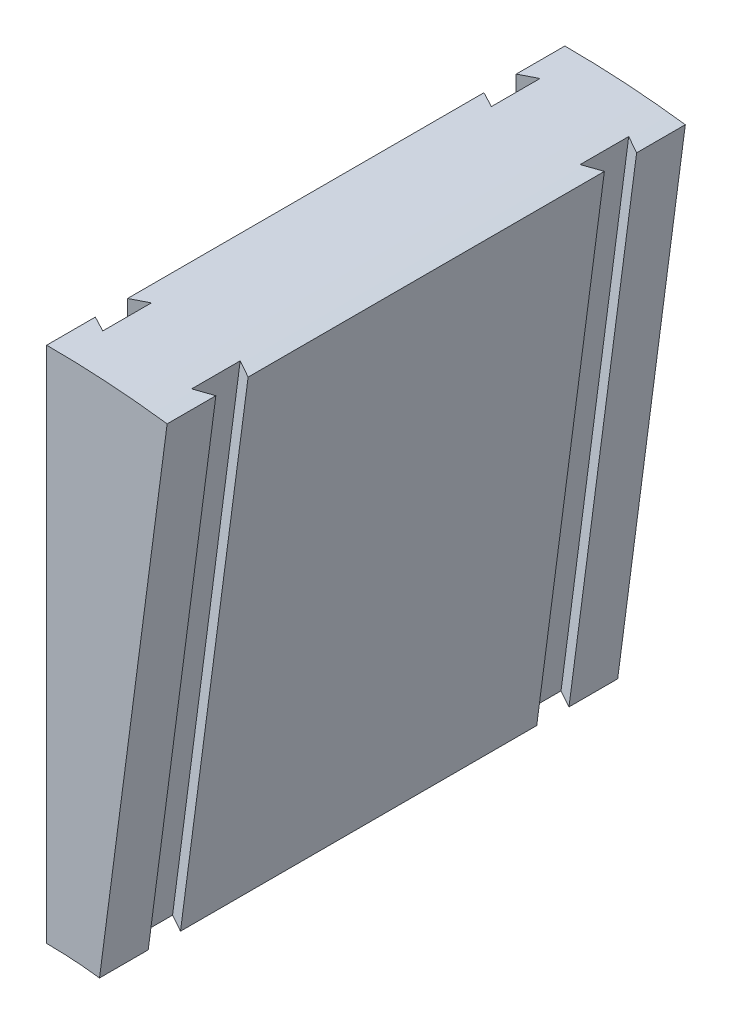
from build123d import *

# Parameters (mm, degrees)
BOSS_EXTRUDE1_DEPTH     = 101.6
CUT_EXTRUDE1_DEPTH      = 2.352318769
CUT_EXTRUDE1_DEPTH_BACK = 104.135020581
CUT_EXTRUDE2_DEPTH      = 1.679064128
CUT_EXTRUDE2_DEPTH_BACK = 102.6


with BuildPart() as part:
    # Sketch1 → Boss-Extrude1 (new body)
    with BuildSketch(Plane.XY):
        with BuildLine():
            Line((0, 79.375), (0, 180.975))
            ThreePointArc((0, 180.975), (11.836331312, 180.587518633), (23.621977637, 179.426733787))
            Line((23.621977637, 179.426733787), (10.360516507, 78.695935872))
            ThreePointArc((10.360516507, 78.695935872), (5.191373383, 79.205052032), (0, 79.375))
        make_face()
    extrude(amount=BOSS_EXTRUDE1_DEPTH)

    # Sketch5 → Cut-Extrude1 (cut, two sides)
    with BuildSketch(Plane(origin=(10.360516507, 78.695935872, 0), x_dir=(0, 0, -1), z_dir=(-0.130526192, -0.991444861, 0))) as cut_extrude1_sk:
        Polygon((-93.64987891, -3.175), (-84.12487891, -3.175), (-85.725, 0), (-92.04975782, 0), align=None)
        Polygon((-15.875, 0), (-17.47512109, -3.175), (-7.95012109, -3.175), (-9.55024218, 0), align=None)
    extrude(amount=CUT_EXTRUDE1_DEPTH, mode=Mode.SUBTRACT)
    extrude(cut_extrude1_sk.sketch, amount=-CUT_EXTRUDE1_DEPTH_BACK, mode=Mode.SUBTRACT)

    # Sketch6 → Cut-Extrude2 (cut, two sides)
    with BuildSketch(Plane(origin=(0, 79.375, 0), x_dir=(0, 0, -1), z_dir=(0, -1, 0))) as cut_extrude2_sk:
        Polygon((-84.1375, 3.059915209), (-93.6625, 3.059915209), (-92.06237891, 0), (-85.73762109, 0), align=None)
        Polygon((-15.86237891, 0), (-17.4625, 3.059915209), (-7.9375, 3.059915209), (-9.53762109, 0), align=None)
    extrude(amount=CUT_EXTRUDE2_DEPTH, mode=Mode.SUBTRACT)
    extrude(cut_extrude2_sk.sketch, amount=-CUT_EXTRUDE2_DEPTH_BACK, mode=Mode.SUBTRACT)


solid = part.part
